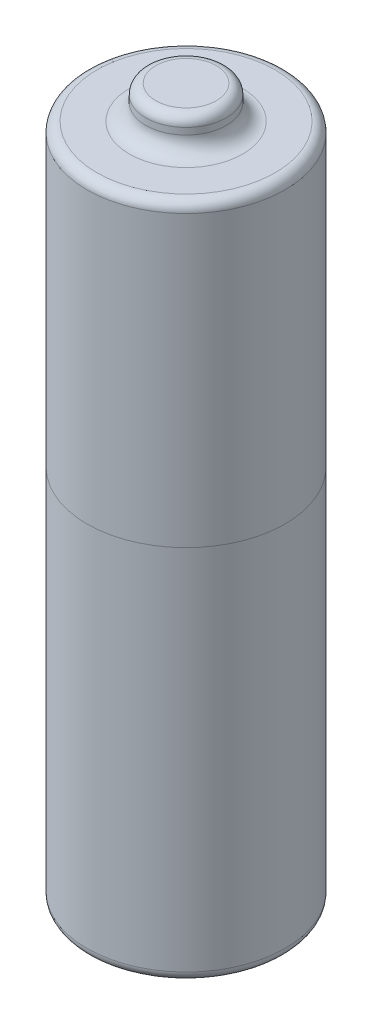
from build123d import *

# Parameters (mm, degrees)
SKETCH2_R           = 7.62
BASE_EXTRUDE_DEPTH  = 52.07
SKETCH3_R           = 3.095145707
BOSS_EXTRUDE1_DEPTH = 2.54
SKETCH4_R           = 6.05891649
BOSS_EXTRUDE2_DEPTH = 0.254
FILLET1_R           = 1.27
FILLET2_R           = 0.762


with BuildPart() as part:
    # Sketch2 → Base-Extrude (new body)
    with BuildSketch(Plane(origin=(0, -6.48413253, 0), x_dir=(-1, 0, 0), z_dir=(0, 1, 0))):
        with Locations((1.569832191, -12.7)):
            Circle(SKETCH2_R)
    extrude(amount=BASE_EXTRUDE_DEPTH)

    # Sketch3 → Boss-Extrude1 (add)
    with BuildSketch(Plane(origin=(0, 45.58586747, 0), x_dir=(-1, 0, 0), z_dir=(0, 1, 0))):
        with Locations((1.569832191, -12.7)):
            Circle(SKETCH3_R)
    extrude(amount=BOSS_EXTRUDE1_DEPTH)

    # Sketch4 → Boss-Extrude2 (add)
    with BuildSketch(Plane.XZ.offset(6.48413253)):
        with Locations((-1.569832191, -12.7)):
            Circle(SKETCH4_R)
    extrude(amount=BOSS_EXTRUDE2_DEPTH)

    # Fillet1
    fillet1_edges = [part.edges().sort_by_distance(p)[0] for p in [
        (1.525313516, 45.58586747, -12.7),
    ]]
    fillet(fillet1_edges, radius=FILLET1_R)

    # Fillet2
    fillet2_edges = [part.edges().sort_by_distance(p)[0] for p in [
        (6.050167809, -6.48413253, -12.7),
        (6.050167809, 45.58586747, -12.7),
        (1.525313516, 48.12586747, -12.7),
    ]]
    fillet(fillet2_edges, radius=FILLET2_R)


solid = part.part
